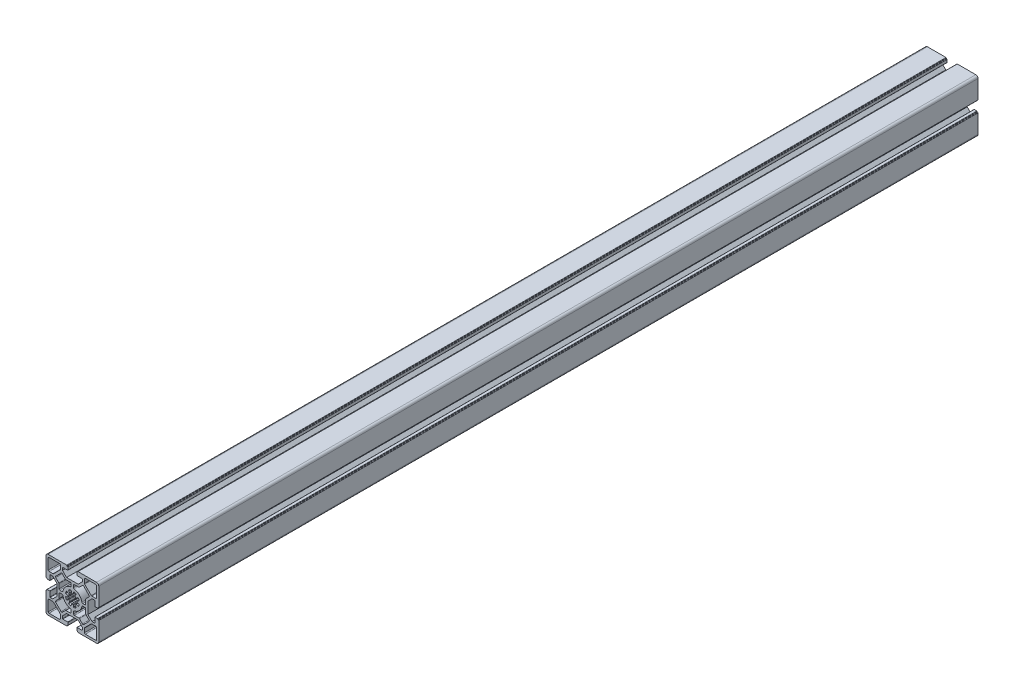
from build123d import *

# Parameters (mm, degrees)
EXTRUDE_1_DEPTH = 1000


with BuildPart() as part:
    # Эскиз1 → Бобышка-Вытянуть1 (new body)
    with BuildSketch(Plane.XY):
        with BuildLine():
            Line((-30, 11.25), (-30, 27.5))
            ThreePointArc((-30, 27.5), (-29.267766953, 29.267766953), (-27.5, 30))
            Line((-27.5, 30), (-11.25, 30))
            Line((-11.25, 30), (-6.4, 30))
            ThreePointArc((-6.4, 30), (-6.187867966, 29.912132034), (-6.1, 29.7))
            Line((-6.1, 29.7), (-6.1, 29.3))
            ThreePointArc((-6.1, 29.3), (-6.012132034, 29.087867966), (-5.8, 29))
            Line((-5.8, 29), (-5.4, 29))
            ThreePointArc((-5.4, 29), (-5.187867966, 28.912132034), (-5.1, 28.7))
            Line((-5.1, 28.7), (-5.1, 25.8))
            ThreePointArc((-5.1, 25.8), (-5.187867966, 25.587867966), (-5.4, 25.5))
            Line((-5.4, 25.5), (-10.95, 25.5))
            ThreePointArc((-10.95, 25.5), (-11.162132034, 25.412132034), (-11.25, 25.2))
            Line((-11.25, 25.2), (-11.25, 22.35))
            Line((-11.25, 22.35), (-6.6, 17.7))
            Line((-6.6, 17.7), (6.6, 17.7))
            Line((6.6, 17.7), (11.25, 22.35))
            Line((11.25, 22.35), (11.25, 25.2))
            ThreePointArc((11.25, 25.2), (11.162132034, 25.412132034), (10.95, 25.5))
            Line((10.95, 25.5), (5.4, 25.5))
            ThreePointArc((5.4, 25.5), (5.187867966, 25.587867966), (5.1, 25.8))
            Line((5.1, 25.8), (5.1, 28.7))
            ThreePointArc((5.1, 28.7), (5.187867966, 28.912132034), (5.4, 29))
            Line((5.4, 29), (5.8, 29))
            ThreePointArc((5.8, 29), (6.012132034, 29.087867966), (6.1, 29.3))
            Line((6.1, 29.3), (6.1, 29.7))
            ThreePointArc((6.1, 29.7), (6.187867966, 29.912132034), (6.4, 30))
            Line((6.4, 30), (11.25, 30))
            Line((11.25, 30), (27.5, 30))
            ThreePointArc((27.5, 30), (29.267766953, 29.267766953), (30, 27.5))
            Line((30, 27.5), (30, 11.25))
            Line((30, 11.25), (30, 6.4))
            ThreePointArc((30, 6.4), (29.912132034, 6.187867966), (29.7, 6.1))
            Line((29.7, 6.1), (29.3, 6.1))
            ThreePointArc((29.3, 6.1), (29.087867966, 6.012132034), (29, 5.8))
            Line((29, 5.8), (29, 5.4))
            ThreePointArc((29, 5.4), (28.912132034, 5.187867966), (28.7, 5.1))
            Line((28.7, 5.1), (25.8, 5.1))
            ThreePointArc((25.8, 5.1), (25.587867966, 5.187867966), (25.5, 5.4))
            Line((25.5, 5.4), (25.5, 10.95))
            ThreePointArc((25.5, 10.95), (25.412132034, 11.162132034), (25.2, 11.25))
            Line((25.2, 11.25), (22.35, 11.25))
            Line((22.35, 11.25), (17.7, 6.6))
            Line((17.7, 6.6), (17.7, -6.6))
            Line((17.7, -6.6), (22.35, -11.25))
            Line((22.35, -11.25), (25.2, -11.25))
            ThreePointArc((25.2, -11.25), (25.412132034, -11.162132034), (25.5, -10.95))
            Line((25.5, -10.95), (25.5, -5.4))
            ThreePointArc((25.5, -5.4), (25.587867966, -5.187867966), (25.8, -5.1))
            Line((25.8, -5.1), (28.7, -5.1))
            ThreePointArc((28.7, -5.1), (28.912132034, -5.187867966), (29, -5.4))
            Line((29, -5.4), (29, -5.8))
            ThreePointArc((29, -5.8), (29.087867966, -6.012132034), (29.3, -6.1))
            Line((29.3, -6.1), (29.7, -6.1))
            ThreePointArc((29.7, -6.1), (29.912132034, -6.187867966), (30, -6.4))
            Line((30, -6.4), (30, -11.25))
            Line((30, -11.25), (30, -27.5))
            ThreePointArc((30, -27.5), (29.267766953, -29.267766953), (27.5, -30))
            Line((27.5, -30), (11.25, -30))
            Line((11.25, -30), (6.4, -30))
            ThreePointArc((6.4, -30), (6.187867966, -29.912132034), (6.1, -29.7))
            Line((6.1, -29.7), (6.1, -29.3))
            ThreePointArc((6.1, -29.3), (6.012132034, -29.087867966), (5.8, -29))
            Line((5.8, -29), (5.4, -29))
            ThreePointArc((5.4, -29), (5.187867966, -28.912132034), (5.1, -28.7))
            Line((5.1, -28.7), (5.1, -25.8))
            ThreePointArc((5.1, -25.8), (5.187867966, -25.587867966), (5.4, -25.5))
            Line((5.4, -25.5), (10.95, -25.5))
            ThreePointArc((10.95, -25.5), (11.162132034, -25.412132034), (11.25, -25.2))
            Line((11.25, -25.2), (11.25, -22.35))
            Line((11.25, -22.35), (6.6, -17.7))
            Line((6.6, -17.7), (-6.6, -17.7))
            Line((-6.6, -17.7), (-11.25, -22.35))
            Line((-11.25, -22.35), (-11.25, -25.2))
            ThreePointArc((-11.25, -25.2), (-11.162132034, -25.412132034), (-10.95, -25.5))
            Line((-10.95, -25.5), (-5.4, -25.5))
            ThreePointArc((-5.4, -25.5), (-5.187867966, -25.587867966), (-5.1, -25.8))
            Line((-5.1, -25.8), (-5.1, -28.7))
            ThreePointArc((-5.1, -28.7), (-5.187867966, -28.912132034), (-5.4, -29))
            Line((-5.4, -29), (-5.8, -29))
            ThreePointArc((-5.8, -29), (-6.012132034, -29.087867966), (-6.1, -29.3))
            Line((-6.1, -29.3), (-6.1, -29.7))
            ThreePointArc((-6.1, -29.7), (-6.187867966, -29.912132034), (-6.4, -30))
            Line((-6.4, -30), (-11.25, -30))
            Line((-11.25, -30), (-27.5, -30))
            ThreePointArc((-27.5, -30), (-29.267766953, -29.267766953), (-30, -27.5))
            Line((-30, -27.5), (-30, -11.25))
            Line((-30, -11.25), (-30, -6.4))
            ThreePointArc((-30, -6.4), (-29.912132034, -6.187867966), (-29.7, -6.1))
            Line((-29.7, -6.1), (-29.3, -6.1))
            ThreePointArc((-29.3, -6.1), (-29.087867966, -6.012132034), (-29, -5.8))
            Line((-29, -5.8), (-29, -5.4))
            ThreePointArc((-29, -5.4), (-28.912132034, -5.187867966), (-28.7, -5.1))
            Line((-28.7, -5.1), (-25.8, -5.1))
            ThreePointArc((-25.8, -5.1), (-25.587867966, -5.187867966), (-25.5, -5.4))
            Line((-25.5, -5.4), (-25.5, -10.95))
            ThreePointArc((-25.5, -10.95), (-25.412132034, -11.162132034), (-25.2, -11.25))
            Line((-25.2, -11.25), (-22.35, -11.25))
            Line((-22.35, -11.25), (-17.7, -6.6))
            Line((-17.7, -6.6), (-17.7, 6.6))
            Line((-17.7, 6.6), (-22.35, 11.25))
            Line((-22.35, 11.25), (-25.2, 11.25))
            ThreePointArc((-25.2, 11.25), (-25.412132034, 11.162132034), (-25.5, 10.95))
            Line((-25.5, 10.95), (-25.5, 5.4))
            ThreePointArc((-25.5, 5.4), (-25.587867966, 5.187867966), (-25.8, 5.1))
            Line((-25.8, 5.1), (-28.7, 5.1))
            ThreePointArc((-28.7, 5.1), (-28.912132034, 5.187867966), (-29, 5.4))
            Line((-29, 5.4), (-29, 5.8))
            ThreePointArc((-29, 5.8), (-29.087867966, 6.012132034), (-29.3, 6.1))
            Line((-29.3, 6.1), (-29.7, 6.1))
            ThreePointArc((-29.7, 6.1), (-29.912132034, 6.187867966), (-30, 6.4))
            Line((-30, 6.4), (-30, 11.25))
        make_face()
        with BuildLine():
            Line((-21.407106781, 13.992893219), (-13.992893219, 21.407106781))
            ThreePointArc((-13.992893219, 21.407106781), (-13.776120467, 21.73153013), (-13.7, 22.114213562))
            Line((-13.7, 22.114213562), (-13.7, 26.5))
            ThreePointArc((-13.7, 26.5), (-13.992893219, 27.207106781), (-14.7, 27.5))
            Line((-14.7, 27.5), (-26.5, 27.5))
            ThreePointArc((-26.5, 27.5), (-27.207106781, 27.207106781), (-27.5, 26.5))
            Line((-27.5, 26.5), (-27.5, 14.7))
            ThreePointArc((-27.5, 14.7), (-27.207106781, 13.992893219), (-26.5, 13.7))
            Line((-26.5, 13.7), (-22.114213562, 13.7))
            ThreePointArc((-22.114213562, 13.7), (-21.73153013, 13.776120467), (-21.407106781, 13.992893219))
        make_face(mode=Mode.SUBTRACT)
        with BuildLine():
            Line((-12.866547622, 18.94766594), (-18.94766594, 12.866547622))
            ThreePointArc((-18.94766594, 12.866547622), (-19.240559159, 12.159440841), (-18.94766594, 11.45233406))
            Line((-18.94766594, 11.45233406), (-15.492893219, 7.997561338))
            ThreePointArc((-15.492893219, 7.997561338), (-15.276120467, 7.673137989), (-15.2, 7.290454557))
            Line((-15.2, 7.290454557), (-15.2, 2.3))
            ThreePointArc((-15.2, 2.3), (-14.907106781, 1.592893219), (-14.2, 1.3))
            Line((-14.2, 1.3), (-11.777520962, 1.3))
            ThreePointArc((-11.777520962, 1.3), (-11.141779924, 1.528097588), (-10.796060881, 2.108333333))
            ThreePointArc((-10.796060881, 2.108333333), (-7.778174593, 7.778174593), (-2.108333333, 10.796060881))
            ThreePointArc((-2.108333333, 10.796060881), (-1.528097588, 11.141779924), (-1.3, 11.777520962))
            Line((-1.3, 11.777520962), (-1.3, 14.2))
            ThreePointArc((-1.3, 14.2), (-1.592893219, 14.907106781), (-2.3, 15.2))
            Line((-2.3, 15.2), (-7.290454557, 15.2))
            ThreePointArc((-7.290454557, 15.2), (-7.673137989, 15.276120467), (-7.997561338, 15.492893219))
            Line((-7.997561338, 15.492893219), (-11.45233406, 18.94766594))
            ThreePointArc((-11.45233406, 18.94766594), (-12.159440841, 19.240559159), (-12.866547622, 18.94766594))
        make_face(mode=Mode.SUBTRACT)
        with BuildLine():
            Line((15.2, 7.290454557), (15.2, 2.3))
            ThreePointArc((15.2, 2.3), (14.907106781, 1.592893219), (14.2, 1.3))
            Line((14.2, 1.3), (11.777520962, 1.3))
            ThreePointArc((11.777520962, 1.3), (11.141779924, 1.528097588), (10.796060881, 2.108333333))
            ThreePointArc((10.796060881, 2.108333333), (7.778174593, 7.778174593), (2.108333333, 10.796060881))
            ThreePointArc((2.108333333, 10.796060881), (1.528097588, 11.141779924), (1.3, 11.777520962))
            Line((1.3, 11.777520962), (1.3, 14.2))
            ThreePointArc((1.3, 14.2), (1.592893219, 14.907106781), (2.3, 15.2))
            Line((2.3, 15.2), (7.290454557, 15.2))
            ThreePointArc((7.290454557, 15.2), (7.673137989, 15.276120467), (7.997561338, 15.492893219))
            Line((7.997561338, 15.492893219), (11.45233406, 18.94766594))
            ThreePointArc((11.45233406, 18.94766594), (12.159440841, 19.240559159), (12.866547622, 18.94766594))
            Line((12.866547622, 18.94766594), (18.94766594, 12.866547622))
            ThreePointArc((18.94766594, 12.866547622), (19.240559159, 12.159440841), (18.94766594, 11.45233406))
            Line((18.94766594, 11.45233406), (15.492893219, 7.997561338))
            ThreePointArc((15.492893219, 7.997561338), (15.276120467, 7.673137989), (15.2, 7.290454557))
        make_face(mode=Mode.SUBTRACT)
        with BuildLine():
            Line((7.290454557, -15.2), (2.3, -15.2))
            ThreePointArc((2.3, -15.2), (1.592893219, -14.907106781), (1.3, -14.2))
            Line((1.3, -14.2), (1.3, -11.777520962))
            ThreePointArc((1.3, -11.777520962), (1.528097588, -11.141779924), (2.108333333, -10.796060881))
            ThreePointArc((2.108333333, -10.796060881), (7.778174593, -7.778174593), (10.796060881, -2.108333333))
            ThreePointArc((10.796060881, -2.108333333), (11.141779924, -1.528097588), (11.777520962, -1.3))
            Line((11.777520962, -1.3), (14.2, -1.3))
            ThreePointArc((14.2, -1.3), (14.907106781, -1.592893219), (15.2, -2.3))
            Line((15.2, -2.3), (15.2, -7.290454557))
            ThreePointArc((15.2, -7.290454557), (15.276120467, -7.673137989), (15.492893219, -7.997561338))
            Line((15.492893219, -7.997561338), (18.94766594, -11.45233406))
            ThreePointArc((18.94766594, -11.45233406), (19.240559159, -12.159440841), (18.94766594, -12.866547622))
            Line((18.94766594, -12.866547622), (12.866547622, -18.94766594))
            ThreePointArc((12.866547622, -18.94766594), (12.159440841, -19.240559159), (11.45233406, -18.94766594))
            Line((11.45233406, -18.94766594), (7.997561338, -15.492893219))
            ThreePointArc((7.997561338, -15.492893219), (7.673137989, -15.276120467), (7.290454557, -15.2))
        make_face(mode=Mode.SUBTRACT)
        with BuildLine():
            Line((-15.2, -7.290454557), (-15.2, -2.3))
            ThreePointArc((-15.2, -2.3), (-14.907106781, -1.592893219), (-14.2, -1.3))
            Line((-14.2, -1.3), (-11.777520962, -1.3))
            ThreePointArc((-11.777520962, -1.3), (-11.141779924, -1.528097588), (-10.796060881, -2.108333333))
            ThreePointArc((-10.796060881, -2.108333333), (-7.778174593, -7.778174593), (-2.108333333, -10.796060881))
            ThreePointArc((-2.108333333, -10.796060881), (-1.528097588, -11.141779924), (-1.3, -11.777520962))
            Line((-1.3, -11.777520962), (-1.3, -14.2))
            ThreePointArc((-1.3, -14.2), (-1.592893219, -14.907106781), (-2.3, -15.2))
            Line((-2.3, -15.2), (-7.290454557, -15.2))
            ThreePointArc((-7.290454557, -15.2), (-7.673137989, -15.276120467), (-7.997561338, -15.492893219))
            Line((-7.997561338, -15.492893219), (-11.45233406, -18.94766594))
            ThreePointArc((-11.45233406, -18.94766594), (-12.159440841, -19.240559159), (-12.866547622, -18.94766594))
            Line((-12.866547622, -18.94766594), (-18.94766594, -12.866547622))
            ThreePointArc((-18.94766594, -12.866547622), (-19.240559159, -12.159440841), (-18.94766594, -11.45233406))
            Line((-18.94766594, -11.45233406), (-15.492893219, -7.997561338))
            ThreePointArc((-15.492893219, -7.997561338), (-15.276120467, -7.673137989), (-15.2, -7.290454557))
        make_face(mode=Mode.SUBTRACT)
        with BuildLine():
            Line((26.5, 13.7), (22.114213562, 13.7))
            ThreePointArc((22.114213562, 13.7), (21.73153013, 13.776120467), (21.407106781, 13.992893219))
            Line((21.407106781, 13.992893219), (13.992893219, 21.407106781))
            ThreePointArc((13.992893219, 21.407106781), (13.776120467, 21.73153013), (13.7, 22.114213562))
            Line((13.7, 22.114213562), (13.7, 26.5))
            ThreePointArc((13.7, 26.5), (13.992893219, 27.207106781), (14.7, 27.5))
            Line((14.7, 27.5), (26.5, 27.5))
            ThreePointArc((26.5, 27.5), (27.207106781, 27.207106781), (27.5, 26.5))
            Line((27.5, 26.5), (27.5, 14.7))
            ThreePointArc((27.5, 14.7), (27.207106781, 13.992893219), (26.5, 13.7))
        make_face(mode=Mode.SUBTRACT)
        with BuildLine():
            Line((13.7, -26.5), (13.7, -22.114213562))
            ThreePointArc((13.7, -22.114213562), (13.776120467, -21.73153013), (13.992893219, -21.407106781))
            Line((13.992893219, -21.407106781), (21.407106781, -13.992893219))
            ThreePointArc((21.407106781, -13.992893219), (21.73153013, -13.776120467), (22.114213562, -13.7))
            Line((22.114213562, -13.7), (26.5, -13.7))
            ThreePointArc((26.5, -13.7), (27.207106781, -13.992893219), (27.5, -14.7))
            Line((27.5, -14.7), (27.5, -26.5))
            ThreePointArc((27.5, -26.5), (27.207106781, -27.207106781), (26.5, -27.5))
            Line((26.5, -27.5), (14.7, -27.5))
            ThreePointArc((14.7, -27.5), (13.992893219, -27.207106781), (13.7, -26.5))
        make_face(mode=Mode.SUBTRACT)
        with BuildLine():
            Line((-26.5, -13.7), (-22.114213562, -13.7))
            ThreePointArc((-22.114213562, -13.7), (-21.73153013, -13.776120467), (-21.407106781, -13.992893219))
            Line((-21.407106781, -13.992893219), (-13.992893219, -21.407106781))
            ThreePointArc((-13.992893219, -21.407106781), (-13.776120467, -21.73153013), (-13.7, -22.114213562))
            Line((-13.7, -22.114213562), (-13.7, -26.5))
            ThreePointArc((-13.7, -26.5), (-13.992893219, -27.207106781), (-14.7, -27.5))
            Line((-14.7, -27.5), (-26.5, -27.5))
            ThreePointArc((-26.5, -27.5), (-27.207106781, -27.207106781), (-27.5, -26.5))
            Line((-27.5, -26.5), (-27.5, -14.7))
            ThreePointArc((-27.5, -14.7), (-27.207106781, -13.992893219), (-26.5, -13.7))
        make_face(mode=Mode.SUBTRACT)
        with BuildLine():
            Line((1.3637258, 7.358005976), (1.016443046, 5.484235912))
            ThreePointArc((1.016443046, 5.484235912), (0.826149864, 5.176357864), (0.477957057, 5.077554239))
            ThreePointArc((0.477957057, 5.077554239), (0, 5.1), (-0.477957057, 5.077554239))
            ThreePointArc((-0.477957057, 5.077554239), (-0.826149864, 5.176357864), (-1.016443046, 5.484235912))
            Line((-1.016443046, 5.484235912), (-1.3637258, 7.358005976))
            ThreePointArc((-1.3637258, 7.358005976), (-1.586050772, 7.688167424), (-1.979043471, 7.751347427))
            ThreePointArc((-1.979043471, 7.751347427), (-3.061467459, 7.39103626), (-4.081635271, 6.880425388))
            ThreePointArc((-4.081635271, 6.880425388), (-4.314848064, 6.557862576), (-4.238596161, 6.167195683))
            Line((-4.238596161, 6.167195683), (-3.159206632, 4.596674173))
            ThreePointArc((-3.159206632, 4.596674173), (-3.076061576, 4.244413919), (-3.252406358, 3.928339711))
            ThreePointArc((-3.252406358, 3.928339711), (-3.606244584, 3.606244584), (-3.928339711, 3.252406358))
            ThreePointArc((-3.928339711, 3.252406358), (-4.244413919, 3.076061576), (-4.596674173, 3.159206632))
            Line((-4.596674173, 3.159206632), (-6.167195683, 4.238596161))
            ThreePointArc((-6.167195683, 4.238596161), (-6.557862576, 4.314848064), (-6.880425388, 4.081635271))
            ThreePointArc((-6.880425388, 4.081635271), (-7.39103626, 3.061467459), (-7.751347427, 1.979043471))
            ThreePointArc((-7.751347427, 1.979043471), (-7.688167424, 1.586050772), (-7.358005976, 1.3637258))
            Line((-7.358005976, 1.3637258), (-5.484235912, 1.016443046))
            ThreePointArc((-5.484235912, 1.016443046), (-5.176357864, 0.826149864), (-5.077554239, 0.477957057))
            ThreePointArc((-5.077554239, 0.477957057), (-5.1, 0), (-5.077554239, -0.477957057))
            ThreePointArc((-5.077554239, -0.477957057), (-5.176357864, -0.826149864), (-5.484235912, -1.016443046))
            Line((-5.484235912, -1.016443046), (-7.358005976, -1.3637258))
            ThreePointArc((-7.358005976, -1.3637258), (-7.688167424, -1.586050772), (-7.751347427, -1.979043471))
            ThreePointArc((-7.751347427, -1.979043471), (-7.39103626, -3.061467459), (-6.880425388, -4.081635271))
            ThreePointArc((-6.880425388, -4.081635271), (-6.557862576, -4.314848064), (-6.167195683, -4.238596161))
            Line((-6.167195683, -4.238596161), (-4.596674173, -3.159206632))
            ThreePointArc((-4.596674173, -3.159206632), (-4.244413919, -3.076061576), (-3.928339711, -3.252406358))
            ThreePointArc((-3.928339711, -3.252406358), (-3.606244584, -3.606244584), (-3.252406358, -3.928339711))
            ThreePointArc((-3.252406358, -3.928339711), (-3.076061576, -4.244413919), (-3.159206632, -4.596674173))
            Line((-3.159206632, -4.596674173), (-4.238596161, -6.167195683))
            ThreePointArc((-4.238596161, -6.167195683), (-4.314848064, -6.557862576), (-4.081635271, -6.880425388))
            ThreePointArc((-4.081635271, -6.880425388), (-3.061467459, -7.39103626), (-1.979043471, -7.751347427))
            ThreePointArc((-1.979043471, -7.751347427), (-1.586050772, -7.688167424), (-1.3637258, -7.358005976))
            Line((-1.3637258, -7.358005976), (-1.016443046, -5.484235912))
            ThreePointArc((-1.016443046, -5.484235912), (-0.826149864, -5.176357864), (-0.477957057, -5.077554239))
            ThreePointArc((-0.477957057, -5.077554239), (0, -5.1), (0.477957057, -5.077554239))
            ThreePointArc((0.477957057, -5.077554239), (0.826149864, -5.176357864), (1.016443046, -5.484235912))
            Line((1.016443046, -5.484235912), (1.3637258, -7.358005976))
            ThreePointArc((1.3637258, -7.358005976), (1.586050772, -7.688167424), (1.979043471, -7.751347427))
            ThreePointArc((1.979043471, -7.751347427), (3.061467459, -7.39103626), (4.081635271, -6.880425388))
            ThreePointArc((4.081635271, -6.880425388), (4.314848064, -6.557862576), (4.238596161, -6.167195683))
            Line((4.238596161, -6.167195683), (3.159206632, -4.596674173))
            ThreePointArc((3.159206632, -4.596674173), (3.076061576, -4.244413919), (3.252406358, -3.928339711))
            ThreePointArc((3.252406358, -3.928339711), (3.606244584, -3.606244584), (3.928339711, -3.252406358))
            ThreePointArc((3.928339711, -3.252406358), (4.244413919, -3.076061576), (4.596674173, -3.159206632))
            Line((4.596674173, -3.159206632), (6.167195683, -4.238596161))
            ThreePointArc((6.167195683, -4.238596161), (6.557862576, -4.314848064), (6.880425388, -4.081635271))
            ThreePointArc((6.880425388, -4.081635271), (7.39103626, -3.061467459), (7.751347427, -1.979043471))
            ThreePointArc((7.751347427, -1.979043471), (7.688167424, -1.586050772), (7.358005976, -1.3637258))
            Line((7.358005976, -1.3637258), (5.484235912, -1.016443046))
            ThreePointArc((5.484235912, -1.016443046), (5.176357864, -0.826149864), (5.077554239, -0.477957057))
            ThreePointArc((5.077554239, -0.477957057), (5.1, 0), (5.077554239, 0.477957057))
            ThreePointArc((5.077554239, 0.477957057), (5.176357864, 0.826149864), (5.484235912, 1.016443046))
            Line((5.484235912, 1.016443046), (7.358005976, 1.3637258))
            ThreePointArc((7.358005976, 1.3637258), (7.688167424, 1.586050772), (7.751347427, 1.979043471))
            ThreePointArc((7.751347427, 1.979043471), (7.39103626, 3.061467459), (6.880425388, 4.081635271))
            ThreePointArc((6.880425388, 4.081635271), (6.557862576, 4.314848064), (6.167195683, 4.238596161))
            Line((6.167195683, 4.238596161), (4.596674173, 3.159206632))
            ThreePointArc((4.596674173, 3.159206632), (4.244413919, 3.076061576), (3.928339711, 3.252406358))
            ThreePointArc((3.928339711, 3.252406358), (3.606244584, 3.606244584), (3.252406358, 3.928339711))
            ThreePointArc((3.252406358, 3.928339711), (3.076061576, 4.244413919), (3.159206632, 4.596674173))
            Line((3.159206632, 4.596674173), (4.238596161, 6.167195683))
            ThreePointArc((4.238596161, 6.167195683), (4.314848064, 6.557862576), (4.081635271, 6.880425388))
            ThreePointArc((4.081635271, 6.880425388), (3.061467459, 7.39103626), (1.979043471, 7.751347427))
            ThreePointArc((1.979043471, 7.751347427), (1.586050772, 7.688167424), (1.3637258, 7.358005976))
        make_face(mode=Mode.SUBTRACT)
    extrude(amount=EXTRUDE_1_DEPTH)


solid = part.part
